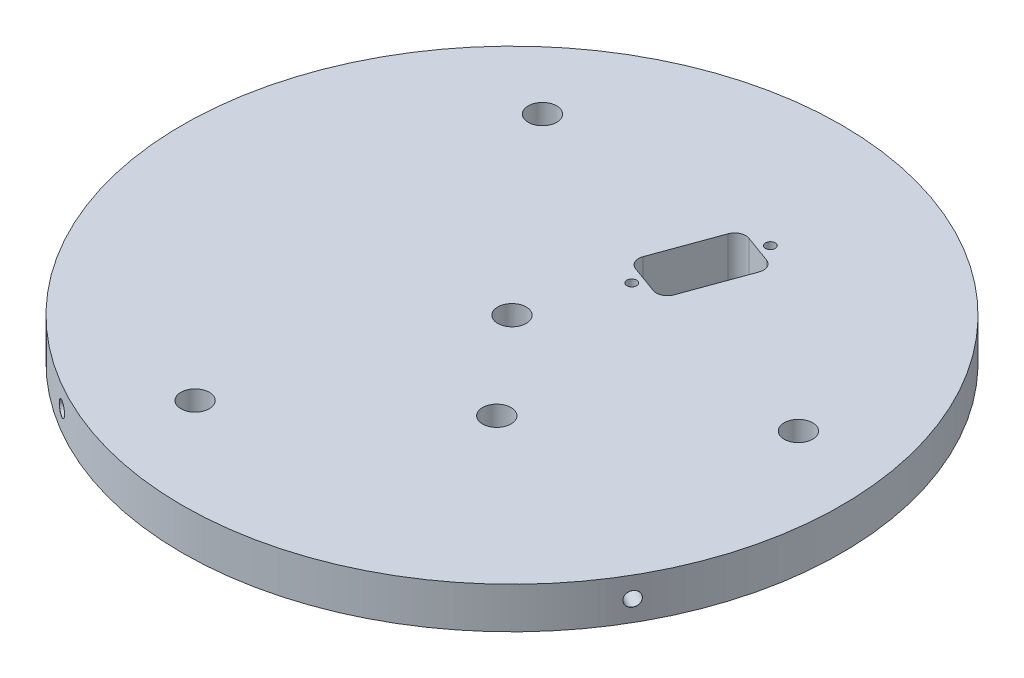
from build123d import *

# Parameters (mm, degrees)
SKETCH1_R                 = 78.359
BOSS_EXTRUDE1_DEPTH       = 25.4
SKETCH6_R                 = 76.1746
BOSS_EXTRUDE5_DEPTH       = 9.525
SKETCH7_R                 = 76.1746
BOSS_EXTRUDE6_DEPTH       = 9.525
SKETCH8_R                 = 73.025
CUT_EXTRUDE5_DEPTH        = 34.925
CUT_EXTRUDE3_START        = 25.4
SKETCH1_7_R               = 78.359
SKETCH1_7_R_2             = 76.1746
CUT_EXTRUDE3_DEPTH        = 9.525
CIRPATTERN2_COUNT         = 3
SKETCH4_R                 = 73.025
BOSS_EXTRUDE4_DEPTH       = 9.525
SKETCH9_R                 = 3.3
CUT_EXTRUDE6_DEPTH        = 45.45
SKETCH10_R                = 82.322787435
CUT_EXTRUDE7_DEPTH        = 35.925
TAP_DRILL_FOR_4_40_TAP1_D = 2.2606
CUT_EXTRUDE9_DEPTH        = 10.525
CIRPATTERN3_COUNT         = 4


with BuildPart() as part:
    # Sketch1 → Boss-Extrude1 (new body)
    with BuildSketch(Plane(origin=(0, 0, 0), x_dir=(1, 0, 0), z_dir=(0, 1, 0))):
        Circle(SKETCH1_R)
    extrude(amount=BOSS_EXTRUDE1_DEPTH)

    # Sketch6 → Boss-Extrude5 (add)
    with BuildSketch(Plane(origin=(0, 25.4, 0), x_dir=(1, 0, 0), z_dir=(0, 1, 0))):
        Circle(SKETCH6_R)
    extrude(amount=BOSS_EXTRUDE5_DEPTH)

    # Sketch7 → Boss-Extrude6 (add)
    with BuildSketch(Plane.XZ):
        Circle(SKETCH7_R)
    extrude(amount=BOSS_EXTRUDE6_DEPTH)

    # Sketch8 → Cut-Extrude5 (cut)
    with BuildSketch(Plane.XZ.offset(9.525)):
        Circle(SKETCH8_R)
    extrude(amount=-CUT_EXTRUDE5_DEPTH, mode=Mode.SUBTRACT)

    # Sketch1_7 → Cut-Extrude3 (cut)
    with BuildSketch(Plane(origin=(0, 0, 0), x_dir=(1, 0, 0), z_dir=(0, 1, 0)).offset(CUT_EXTRUDE3_START)):
        Circle(SKETCH1_7_R)
        Circle(SKETCH1_7_R_2, mode=Mode.SUBTRACT)
    cut_extrude3 = extrude(amount=-CUT_EXTRUDE3_DEPTH, mode=Mode.SUBTRACT)

    # CirPattern2: Cut-Extrude3 ×3 about axis
    cirpattern2_axis = Axis((0, 0, 0), (0, 1, 0))
    for i in range(1, CIRPATTERN2_COUNT):
        add(cut_extrude3.rotate(cirpattern2_axis, i * 360 / CIRPATTERN2_COUNT), mode=Mode.SUBTRACT)

    # Sketch4 → Boss-Extrude4 (add)
    with BuildSketch(Plane(origin=(0, 34.925, 0), x_dir=(1, 0, 0), z_dir=(0, 1, 0))):
        Circle(SKETCH4_R)
    extrude(amount=-BOSS_EXTRUDE4_DEPTH)

    # Sketch9 → Cut-Extrude6 (cut, through all)
    with BuildSketch(Plane(origin=(0, 34.925, 0), x_dir=(1, 0, 0), z_dir=(0, 1, 0))):
        Circle(SKETCH9_R)
        with Locations((-19.546451191, -53.703433278)):
            Circle(SKETCH9_R)
        with Locations((-36.735311894, 43.779439924)):
            Circle(SKETCH9_R)
        with Locations((56.281763085, 9.923993354)):
            Circle(SKETCH9_R)
        with Locations((18.367655947, -21.889719962)):
            Circle(SKETCH9_R)
    extrude(amount=-CUT_EXTRUDE6_DEPTH, mode=Mode.SUBTRACT)

    # Sketch10 → Cut-Extrude7 (cut, through all)
    with BuildSketch(Plane(origin=(0, 25.4, 0), x_dir=(1, 0, 0), z_dir=(0, 1, 0))):
        Circle(SKETCH10_R)
    extrude(amount=-CUT_EXTRUDE7_DEPTH, mode=Mode.SUBTRACT)

    # Tap Drill for _4-40 Tap1 (through all)
    with Locations(Plane(origin=(0, 34.925, 0), x_dir=(1, 0, 0), z_dir=(0, 1, 0))):
        with Locations((7.384214894, 20.287963683), (15.934718491, 43.780279238)):
            Hole(TAP_DRILL_FOR_4_40_TAP1_D / 2)

    # Sketch14 → Cut-Extrude9 (cut, through all)
    with BuildSketch(Plane(origin=(0, 34.925, 0), x_dir=(1, 0, 0), z_dir=(0, 1, 0))):
        with BuildLine():
            Line((14.64382936, 22.781402035), (19.893154532, 37.203804415))
            ThreePointArc((19.893154532, 37.203804415), (19.808357055, 39.145985964), (18.37506644, 40.459354836))
            Line((18.37506644, 40.459354836), (11.930654446, 42.804928978))
            ThreePointArc((11.930654446, 42.804928978), (9.988472897, 42.720131501), (8.675104025, 41.286840886))
            Line((8.675104025, 41.286840886), (3.425778853, 26.864438506))
            ThreePointArc((3.425778853, 26.864438506), (3.51057633, 24.922256957), (4.943866945, 23.608888085))
            Line((4.943866945, 23.608888085), (11.388278939, 21.263313942))
            ThreePointArc((11.388278939, 21.263313942), (13.330460488, 21.34811142), (14.64382936, 22.781402035))
        make_face()
    extrude(amount=-CUT_EXTRUDE9_DEPTH, mode=Mode.SUBTRACT)

    # Sketch19 → Tap Drill for M4x0.7 Tap1 (revolve, cut)
    with BuildSketch(Plane(origin=(-38.0873, 30.1625, 65.969138723), x_dir=(0.866025404, 0, 0.5), z_dir=(0, 1, 0))):
        Polygon((0, 0), (0, 10.991425421), (1.65, 10.0000054), (1.65, 0.025), (1.675, 0), align=None)
    tap_drill_for_m4x0_7_tap1 = revolve(axis=Axis((-41.2623, 30.1625, 71.468400037), (0.5, 0, -0.866025404)), mode=Mode.SUBTRACT)

    # CirPattern3: Tap Drill for M4x0.7 Tap1 ×4 about axis
    cirpattern3_axis = Axis((0, 34.925, 0), (0, 1, 0))
    for i in range(1, CIRPATTERN3_COUNT):
        add(tap_drill_for_m4x0_7_tap1.rotate(cirpattern3_axis, i * 360 / CIRPATTERN3_COUNT), mode=Mode.SUBTRACT)


solid = part.part
